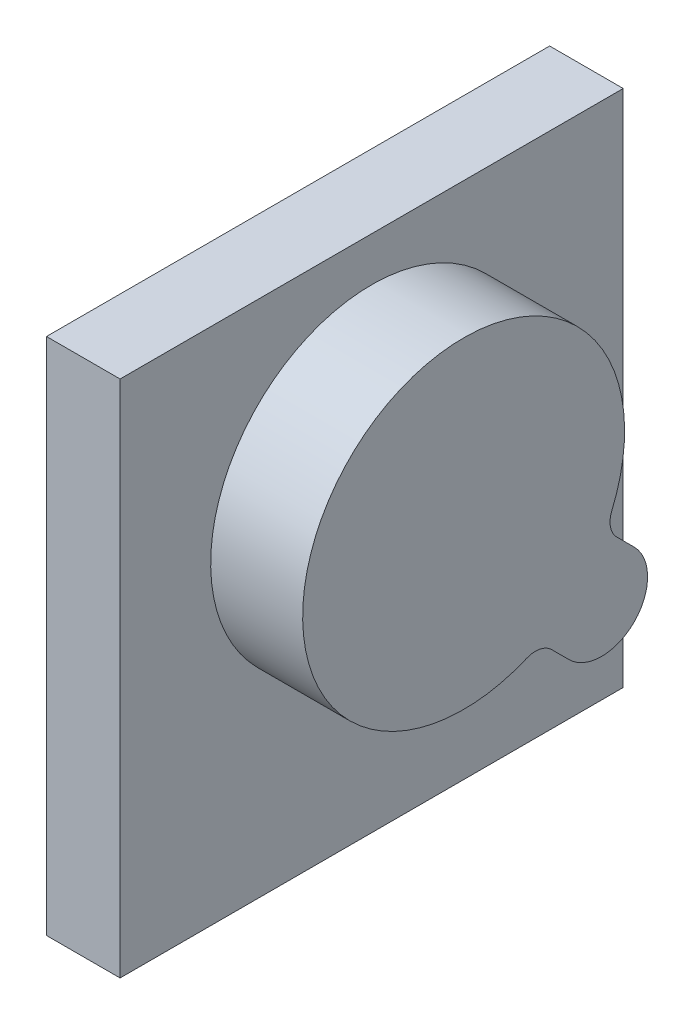
from build123d import *

# Parameters (mm, degrees)
SKETCH1_W           = 138.938
SKETCH1_H           = 143.256
BOSS_EXTRUDE1_DEPTH = 20.32
BOSS_EXTRUDE2_DEPTH = 25.4


with BuildPart() as part:
    # Sketch1 → Boss-Extrude1 (new body)
    with BuildSketch(Plane(origin=(0, 0, 0), x_dir=(0, 0, -1), z_dir=(1, 0, 0))):
        Rectangle(SKETCH1_W, SKETCH1_H)
    extrude(amount=-BOSS_EXTRUDE1_DEPTH)

    # Sketch2 → Boss-Extrude2 (add)
    with BuildSketch(Plane(origin=(0, 0, 0), x_dir=(0, 0, -1), z_dir=(1, 0, 0))):
        with BuildLine():
            Line((47.080256121, -14.133743879), (42.27993705, -9.333424808))
            ThreePointArc((42.27993705, -9.333424808), (40.536989709, -6.056256364), (40.923806972, -2.364634654))
            ThreePointArc((40.923806972, -2.364634654), (-31.430896424, 46.416896424), (17.350634654, -25.937806972))
            ThreePointArc((17.350634654, -25.937806972), (21.042256364, -25.550989709), (24.319424808, -27.29393705))
            Line((24.319424808, -27.29393705), (29.119743879, -32.094256121))
            ThreePointArc((29.119743879, -32.094256121), (47.080256121, -32.094256121), (47.080256121, -14.133743879))
        make_face()
    extrude(amount=BOSS_EXTRUDE2_DEPTH)


solid = part.part
